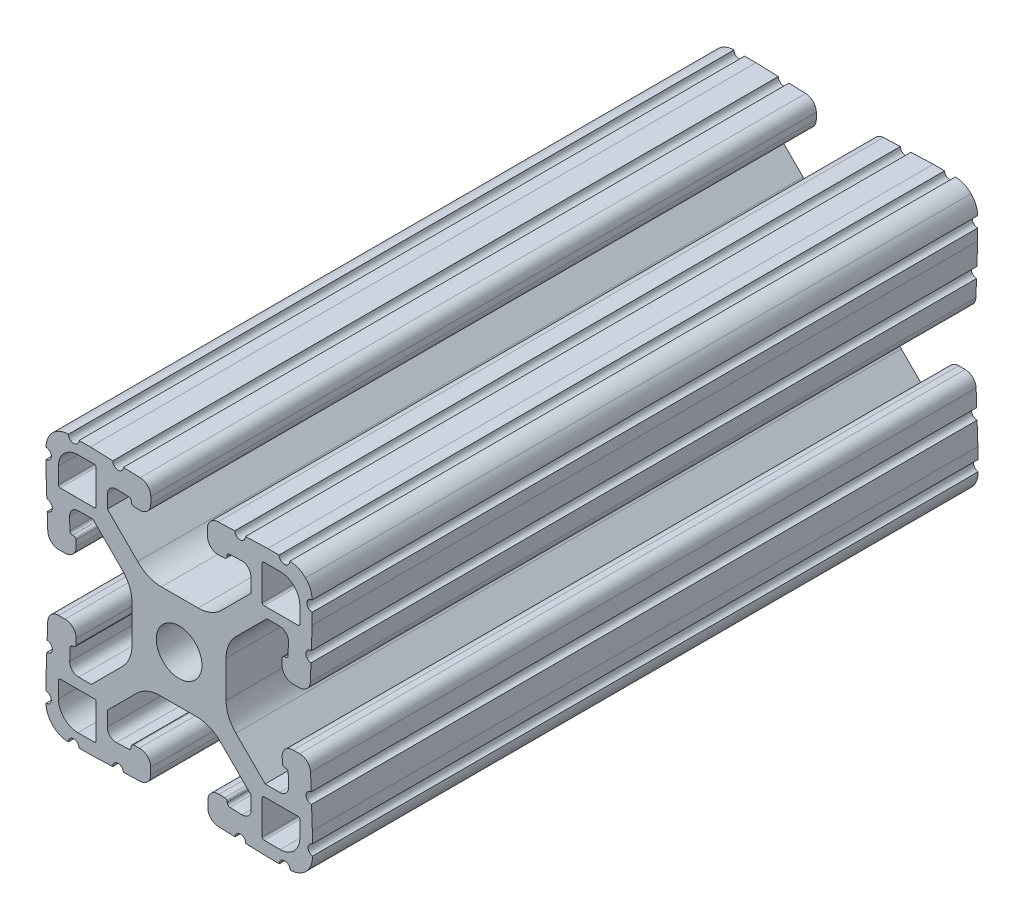
from build123d import *

# Parameters (mm, degrees)
SKETCH1_R           = 3.2639
BOSS_EXTRUDE1_DEPTH = 95.25


with BuildPart() as part:
    # Sketch1 → Boss-Extrude1 (new body)
    with BuildSketch(Plane(origin=(0, 0, -25.4), x_dir=(-1, 0, 0), z_dir=(0, 0, -1))):
        with BuildLine():
            Line((-88.043721549, 91.862643967), (-86.29674679, 91.923648859))
            ThreePointArc((-86.29674679, 91.923648859), (-85.370208675, 91.567983831), (-84.982425017, 90.654422489))
            Line((-84.982425017, 90.654422489), (-84.982425017, 88.800173916))
            Line((-84.982425017, 88.800173916), (-89.306565884, 84.476033049))
            ThreePointArc((-89.306565884, 84.476033049), (-90.866149908, 83.406077005), (-92.719610366, 83.029523439))
            Line((-92.719610366, 83.029523439), (-97.961628589, 83.029523439))
            ThreePointArc((-97.961628589, 83.029523439), (-99.779298356, 83.391080435), (-101.320244378, 84.42070765))
            Line((-101.320244378, 84.42070765), (-105.516001761, 88.616465033))
            Line((-105.516001761, 88.616465033), (-105.516001761, 90.731330035))
            ThreePointArc((-105.516001761, 90.731330035), (-105.128218103, 91.644891377), (-104.201679988, 92.000556406))
            Line((-104.201679988, 92.000556406), (-102.454705229, 91.939551513))
            ThreePointArc((-102.454705229, 91.939551513), (-102.193933359, 91.823448504), (-102.087001761, 91.558783602))
            ThreePointArc((-102.087001761, 91.558783602), (-102.010859042, 91.249291513), (-101.726191901, 91.105946874))
            Line((-101.726191901, 91.105946874), (-100.929727576, 91.078102142))
            ThreePointArc((-100.929727576, 91.078102142), (-99.780779944, 91.519102656), (-99.299905511, 92.651940638))
            Line((-99.299905511, 92.651940638), (-99.299905511, 93.566848638))
            ThreePointArc((-99.299905511, 93.566848638), (-99.741889517, 94.660796975), (-100.819746715, 95.140689345))
            Line((-100.819746715, 95.140689345), (-103.211918901, 95.224224422))
            ThreePointArc((-103.211918901, 95.224224422), (-104.000045777, 94.489281495), (-104.734990687, 95.277406522))
            Line((-104.734990687, 95.277406522), (-107.935905676, 95.389166912))
            Line((-107.935905676, 95.389166912), (-109.561454876, 95.389166912))
            ThreePointArc((-109.561454876, 95.389166912), (-110.323454876, 94.627166912), (-111.085454876, 95.389166912))
            ThreePointArc((-111.085454876, 95.389166912), (-112.308767787, 95.144035599), (-113.343184761, 94.446493225))
            ThreePointArc((-113.343184761, 94.446493225), (-114.04072548, 93.412075135), (-114.285854836, 92.188761832))
            ThreePointArc((-114.285854836, 92.188761832), (-113.523853616, 91.426762441), (-114.285853616, 90.664761832))
            Line((-114.285853616, 90.664761832), (-114.285853616, 89.039212632))
            Line((-114.285853616, 89.039212632), (-114.174093219, 85.838297643))
            ThreePointArc((-114.174093219, 85.838297643), (-113.385968191, 85.103352735), (-114.120911115, 84.315225857))
            Line((-114.120911115, 84.315225857), (-114.037376031, 81.923053667))
            ThreePointArc((-114.037376031, 81.923053667), (-113.55748366, 80.845196472), (-112.463535325, 80.403212468))
            Line((-112.463535325, 80.403212468), (-111.548627325, 80.403212468))
            ThreePointArc((-111.548627325, 80.403212468), (-110.415788905, 80.884087354), (-109.974788872, 82.033035791))
            Line((-109.974788872, 82.033035791), (-110.002634241, 82.829500094))
            ThreePointArc((-110.002634241, 82.829500094), (-110.118742417, 83.090261917), (-110.383401914, 83.197188))
            ThreePointArc((-110.383401914, 83.197188), (-110.693757401, 83.272605688), (-110.837665276, 83.557735272))
            Line((-110.837665276, 83.557735272), (-110.898671566, 85.304709982))
            ThreePointArc((-110.898671566, 85.304709982), (-110.543006925, 86.231248747), (-109.62944523, 86.61903277))
            Line((-109.62944523, 86.61903277), (-107.807161806, 86.61903277))
            Line((-107.807161806, 86.61903277), (-103.364925613, 82.176810793))
            ThreePointArc((-103.364925613, 82.176810793), (-102.335294479, 80.635862907), (-101.973736029, 78.81818963))
            Line((-101.973736029, 78.81818963), (-101.973736029, 73.576034207))
            ThreePointArc((-101.973736029, 73.576034207), (-102.335293752, 71.758362684), (-103.364922926, 70.21741573))
            Line((-103.364922926, 70.21741573), (-107.560683666, 66.021661704))
            Line((-107.560683666, 66.021661704), (-109.652436558, 66.021661704))
            ThreePointArc((-109.652436558, 66.021661704), (-110.565998503, 66.409445617), (-110.921663765, 67.335984343))
            Line((-110.921663765, 67.335984343), (-110.860658873, 69.082959102))
            ThreePointArc((-110.860658873, 69.082959102), (-110.744555864, 69.343730973), (-110.479890961, 69.45066257))
            ThreePointArc((-110.479890961, 69.45066257), (-110.173494703, 69.529390272), (-110.032185196, 69.812424443))
            Line((-110.032185196, 69.812424443), (-110.004340464, 70.608888768))
            ThreePointArc((-110.004340464, 70.608888768), (-110.445340978, 71.7578364), (-111.57817896, 72.238710833))
            Line((-111.57817896, 72.238710833), (-112.49308696, 72.238710833))
            ThreePointArc((-112.49308696, 72.238710833), (-113.587035297, 71.796726827), (-114.066927667, 70.718869629))
            Line((-114.066927667, 70.718869629), (-114.150462744, 68.326697443))
            ThreePointArc((-114.150462744, 68.326697443), (-113.415519817, 67.538570567), (-114.203644843, 66.803625657))
            Line((-114.203644843, 66.803625657), (-114.315405233, 63.602710668))
            Line((-114.315405233, 63.602710668), (-114.315405233, 61.962557497))
            ThreePointArc((-114.315405233, 61.962557497), (-113.701927281, 61.206106537), (-114.333208228, 60.464447842))
            ThreePointArc((-114.333208228, 60.464447842), (-114.113020459, 59.176546471), (-113.392816136, 58.086372941))
            ThreePointArc((-113.392816136, 58.086372941), (-112.358398046, 57.388832223), (-111.135084743, 57.143702867))
            ThreePointArc((-111.135084743, 57.143702867), (-110.373085352, 57.905704086), (-109.611084743, 57.143704086))
            Line((-109.611084743, 57.143704086), (-107.985535543, 57.143704086))
            Line((-107.985535543, 57.143704086), (-104.784620554, 57.255464483))
            ThreePointArc((-104.784620554, 57.255464483), (-104.049675645, 58.04358951), (-103.261548768, 57.308646586))
            Line((-103.261548768, 57.308646586), (-100.869376578, 57.39218167))
            ThreePointArc((-100.869376578, 57.39218167), (-99.791519383, 57.872074041), (-99.349535378, 58.966022376))
            Line((-99.349535378, 58.966022376), (-99.349535378, 59.880930376))
            ThreePointArc((-99.349535378, 59.880930376), (-99.830409811, 61.013768358), (-100.979357443, 61.454768873))
            Line((-100.979357443, 61.454768873), (-101.775821768, 61.42692414))
            ThreePointArc((-101.775821768, 61.42692414), (-102.036583684, 61.310816174), (-102.143509978, 61.046156762))
            ThreePointArc((-102.143509978, 61.046156762), (-102.222494916, 60.740061862), (-102.505377386, 60.598958297))
            Line((-102.505377386, 60.598958297), (-104.252352145, 60.537953405))
            ThreePointArc((-104.252352145, 60.537953405), (-105.17889026, 60.893618433), (-105.566673918, 61.807179775))
            Line((-105.566673918, 61.807179775), (-105.566673918, 63.629462758))
            Line((-105.566673918, 63.629462758), (-101.131142468, 68.064994208))
            ThreePointArc((-101.131142468, 68.064994208), (-99.590196446, 69.094621422), (-97.772526678, 69.456178419))
            Line((-97.772526678, 69.456178419), (-92.530356056, 69.456178419))
            ThreePointArc((-92.530356056, 69.456178419), (-90.712686289, 69.094621422), (-89.171740267, 68.064994208))
            Line((-89.171740267, 68.064994208), (-84.975982884, 63.869236825))
            Line((-84.975982884, 63.869236825), (-84.975982884, 61.781050107))
            ThreePointArc((-84.975982884, 61.781050107), (-85.363766542, 60.867488765), (-86.290304657, 60.511823736))
            Line((-86.290304657, 60.511823736), (-88.037279416, 60.572828629))
            ThreePointArc((-88.037279416, 60.572828629), (-88.298051286, 60.688931638), (-88.404982884, 60.95359654))
            ThreePointArc((-88.404982884, 60.95359654), (-88.466593694, 61.278962759), (-88.759626911, 61.433204782))
            Line((-88.759626911, 61.433204782), (-89.556091237, 61.461049514))
            ThreePointArc((-89.556091237, 61.461049514), (-90.705038868, 61.020049), (-91.185913301, 59.887211018))
            Line((-91.185913301, 59.887211018), (-91.185913301, 58.972303018))
            ThreePointArc((-91.185913301, 58.972303018), (-90.743929295, 57.878354681), (-89.666072098, 57.398462311))
            Line((-89.666072098, 57.398462311), (-87.273899911, 57.314927234))
            ThreePointArc((-87.273899911, 57.314927234), (-86.485773036, 58.049870161), (-85.750828126, 57.261745135))
            Line((-85.750828126, 57.261745135), (-82.549913136, 57.149984745))
            Line((-82.549913136, 57.149984745), (-80.924363936, 57.149984745))
            ThreePointArc((-80.924363936, 57.149984745), (-80.162363936, 57.911984745), (-79.400363936, 57.149984745))
            ThreePointArc((-79.400363936, 57.149984745), (-78.177051025, 57.395116058), (-77.142634052, 58.092658432))
            ThreePointArc((-77.142634052, 58.092658432), (-76.445094372, 59.127074031), (-76.199963977, 60.350384428))
            ThreePointArc((-76.199963977, 60.350384428), (-76.961961268, 61.112385783), (-76.199961268, 61.874384428))
            Line((-76.199961268, 61.874384428), (-76.199961268, 63.499933628))
            Line((-76.199961268, 63.499933628), (-76.311721666, 66.700848617))
            ThreePointArc((-76.311721666, 66.700848617), (-77.099846694, 67.435793525), (-76.364903769, 68.223920403))
            Line((-76.364903769, 68.223920403), (-76.448438853, 70.616092593))
            ThreePointArc((-76.448438853, 70.616092593), (-76.928331225, 71.693949788), (-78.02227956, 72.135933792))
            Line((-78.02227956, 72.135933792), (-78.93718756, 72.135933792))
            ThreePointArc((-78.93718756, 72.135933792), (-80.07002598, 71.655058906), (-80.511026012, 70.506110469))
            Line((-80.511026012, 70.506110469), (-80.483180643, 69.709646166))
            ThreePointArc((-80.483180643, 69.709646166), (-80.367072468, 69.448884343), (-80.102412971, 69.34195826))
            ThreePointArc((-80.102412971, 69.34195826), (-79.796317908, 69.262973649), (-79.655214052, 68.980091239))
            Line((-79.655214052, 68.980091239), (-79.594207761, 67.233116529))
            ThreePointArc((-79.594207761, 67.233116529), (-79.949872402, 66.306577764), (-80.863434097, 65.918793741))
            Line((-80.863434097, 65.918793741), (-82.685717521, 65.918793741))
            Line((-82.685717521, 65.918793741), (-87.121258001, 70.35431293))
            ThreePointArc((-87.121258001, 70.35431293), (-88.150863946, 71.895196205), (-88.512450271, 73.712794894))
            Line((-88.512450271, 73.712794894), (-88.512606864, 78.954950317))
            ThreePointArc((-88.512606864, 78.954950317), (-88.151076291, 80.772698182), (-87.121419968, 82.313710679))
            Line((-87.121419968, 82.313710679), (-82.925659228, 86.509464706))
            Line((-82.925659228, 86.509464706), (-80.837473527, 86.509464706))
            ThreePointArc((-80.837473527, 86.509464706), (-79.923911584, 86.121680793), (-79.568246321, 85.195142068))
            Line((-79.568246321, 85.195142068), (-79.629251214, 83.448167309))
            ThreePointArc((-79.629251214, 83.448167309), (-79.745354223, 83.187395438), (-80.010019125, 83.080463841))
            ThreePointArc((-80.010019125, 83.080463841), (-80.335385344, 83.018853031), (-80.489627367, 82.725819813))
            Line((-80.489627367, 82.725819813), (-80.5174721, 81.929355488))
            ThreePointArc((-80.5174721, 81.929355488), (-80.076471586, 80.780407856), (-78.943633603, 80.299533423))
            Line((-78.943633603, 80.299533423), (-78.028725603, 80.299533423))
            ThreePointArc((-78.028725603, 80.299533423), (-76.934777267, 80.741517429), (-76.454884897, 81.819374627))
            Line((-76.454884897, 81.819374627), (-76.37134982, 84.211546813))
            ThreePointArc((-76.37134982, 84.211546813), (-77.106292747, 84.999673689), (-76.31816772, 85.734618599))
            Line((-76.31816772, 85.734618599), (-76.20640733, 88.935533588))
            Line((-76.20640733, 88.935533588), (-76.20640733, 90.561082788))
            ThreePointArc((-76.20640733, 90.561082788), (-76.96840733, 91.323083398), (-76.206406111, 92.085082788))
            ThreePointArc((-76.206406111, 92.085082788), (-76.451535467, 93.308396091), (-77.149076185, 94.342814181))
            ThreePointArc((-77.149076185, 94.342814181), (-78.183493159, 95.040356555), (-79.40680607, 95.285487868))
            ThreePointArc((-79.40680607, 95.285487868), (-80.16880607, 94.523487868), (-80.93080607, 95.285487868))
            Line((-80.93080607, 95.285487868), (-82.55635527, 95.285487868))
            Line((-82.55635527, 95.285487868), (-85.757270259, 95.173727471))
            ThreePointArc((-85.757270259, 95.173727471), (-86.492215168, 94.385602444), (-87.280342045, 95.120545368))
            Line((-87.280342045, 95.120545368), (-89.672514235, 95.037010285))
            ThreePointArc((-89.672514235, 95.037010285), (-90.75037143, 94.557117913), (-91.192355435, 93.463169578))
            Line((-91.192355435, 93.463169578), (-91.192355435, 92.548261578))
            ThreePointArc((-91.192355435, 92.548261578), (-90.711481002, 91.415423596), (-89.56253337, 90.974423082))
            Line((-89.56253337, 90.974423082), (-88.766069045, 91.002267814))
            ThreePointArc((-88.766069045, 91.002267814), (-88.505307129, 91.11837578), (-88.398380835, 91.383035192))
            ThreePointArc((-88.398380835, 91.383035192), (-88.336765486, 91.708407548), (-88.043721549, 91.862643967))
        make_face()
        with Locations(Location((-95.25, 76.2, 0), (0, 0, 180))):  # turned: the seam where the file's is
            Circle(SKETCH1_R, mode=Mode.SUBTRACT)
        with BuildLine():
            Line((-83.357745393, 88.294108398), (-83.357745393, 93.170908398))
            ThreePointArc((-83.357745393, 93.170908398), (-83.283351492, 93.350512545), (-83.103748154, 93.424908398))
            Line((-83.103748154, 93.424908398), (-80.766975763, 93.424933798))
            ThreePointArc((-80.766975763, 93.424933798), (-78.791299784, 92.606600882), (-77.972945393, 90.630933798))
            Line((-77.972945393, 90.630933798), (-77.972945393, 88.294108398))
            ThreePointArc((-77.972945393, 88.294108398), (-78.047340271, 88.114503276), (-78.226945393, 88.040108398))
            Line((-78.226945393, 88.040108398), (-83.103745393, 88.040108398))
            ThreePointArc((-83.103745393, 88.040108398), (-83.283350516, 88.114503276), (-83.357745393, 88.294108398))
        make_face(mode=Mode.SUBTRACT)
        with BuildLine():
            Line((-83.357745393, 59.229091602), (-83.357745393, 64.105891602))
            ThreePointArc((-83.357745393, 64.105891602), (-83.283350516, 64.285496724), (-83.103745393, 64.359891602))
            Line((-83.103745393, 64.359891602), (-78.226945393, 64.359891602))
            ThreePointArc((-78.226945393, 64.359891602), (-78.047340271, 64.285496724), (-77.972945393, 64.105891602))
            Line((-77.972945393, 64.105891602), (-77.972945393, 61.769066202))
            ThreePointArc((-77.972945393, 61.769066202), (-78.791299784, 59.793399118), (-80.766975763, 58.975066202))
            Line((-80.766975763, 58.975066202), (-83.103748154, 58.975091602))
            ThreePointArc((-83.103748154, 58.975091602), (-83.283351492, 59.049487455), (-83.357745393, 59.229091602))
        make_face(mode=Mode.SUBTRACT)
        with BuildLine():
            Line((-107.142254607, 93.170908398), (-107.142254607, 88.294108398))
            ThreePointArc((-107.142254607, 88.294108398), (-107.216649484, 88.114503276), (-107.396254607, 88.040108398))
            Line((-107.396254607, 88.040108398), (-112.273054607, 88.040108398))
            ThreePointArc((-112.273054607, 88.040108398), (-112.452659729, 88.114503276), (-112.527054607, 88.294108398))
            Line((-112.527054607, 88.294108398), (-112.527054607, 90.630933798))
            ThreePointArc((-112.527054607, 90.630933798), (-111.708700216, 92.606600882), (-109.733024237, 93.424933798))
            Line((-109.733024237, 93.424933798), (-107.396251846, 93.424908398))
            ThreePointArc((-107.396251846, 93.424908398), (-107.216648508, 93.350512545), (-107.142254607, 93.170908398))
        make_face(mode=Mode.SUBTRACT)
        with BuildLine():
            Line((-107.142254607, 64.105891602), (-107.142254607, 59.229091602))
            ThreePointArc((-107.142254607, 59.229091602), (-107.216648508, 59.049487455), (-107.396251846, 58.975091602))
            Line((-107.396251846, 58.975091602), (-109.733024237, 58.975066202))
            ThreePointArc((-109.733024237, 58.975066202), (-111.708700216, 59.793399118), (-112.527054607, 61.769066202))
            Line((-112.527054607, 61.769066202), (-112.527054607, 64.105891602))
            ThreePointArc((-112.527054607, 64.105891602), (-112.452659729, 64.285496724), (-112.273054607, 64.359891602))
            Line((-112.273054607, 64.359891602), (-107.396254607, 64.359891602))
            ThreePointArc((-107.396254607, 64.359891602), (-107.216649484, 64.285496724), (-107.142254607, 64.105891602))
        make_face(mode=Mode.SUBTRACT)
    extrude(amount=-BOSS_EXTRUDE1_DEPTH)


solid = part.part
